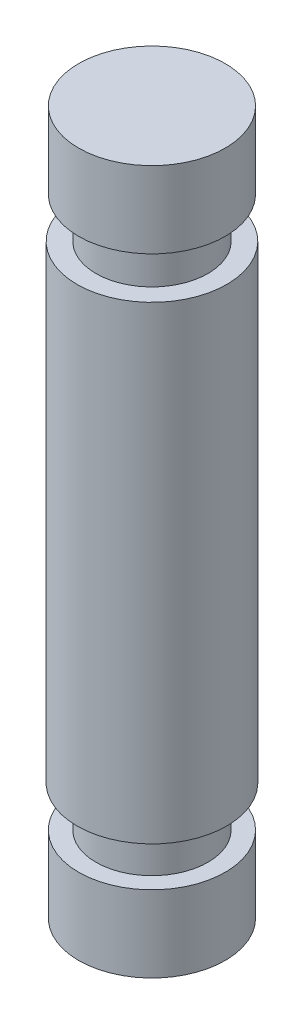
from build123d import *

# Parameters (mm, degrees)
SKETCH2_R           = 3.5
BOSS_EXTRUDE1_DEPTH = 3.65
SKETCH3_R           = 2.675
BOSS_EXTRUDE2_DEPTH = 1.95
SKETCH4_R           = 3.575
BOSS_EXTRUDE3_DEPTH = 22.4
SKETCH5_R           = 2.675
BOSS_EXTRUDE4_DEPTH = 1.95
SKETCH6_R           = 3.5
BOSS_EXTRUDE5_DEPTH = 3.65


with BuildPart() as part:
    # Sketch2 → Boss-Extrude1 (new body)
    with BuildSketch(Plane(origin=(0, 0, 0), x_dir=(1, 0, 0), z_dir=(0, 1, 0))):
        Circle(SKETCH2_R)
    extrude(amount=BOSS_EXTRUDE1_DEPTH)

    # Sketch3 → Boss-Extrude2 (add)
    with BuildSketch(Plane(origin=(0, 3.65, 0), x_dir=(1, 0, 0), z_dir=(0, 1, 0))):
        Circle(SKETCH3_R)
    extrude(amount=BOSS_EXTRUDE2_DEPTH)

    # Sketch4 → Boss-Extrude3 (add)
    with BuildSketch(Plane(origin=(0, 5.6, 0), x_dir=(1, 0, 0), z_dir=(0, 1, 0))):
        Circle(SKETCH4_R)
    extrude(amount=BOSS_EXTRUDE3_DEPTH)

    # Sketch5 → Boss-Extrude4 (add)
    with BuildSketch(Plane(origin=(0, 28, 0), x_dir=(1, 0, 0), z_dir=(0, 1, 0))):
        Circle(SKETCH5_R)
    extrude(amount=BOSS_EXTRUDE4_DEPTH)

    # Sketch6 → Boss-Extrude5 (add)
    with BuildSketch(Plane(origin=(0, 29.95, 0), x_dir=(1, 0, 0), z_dir=(0, 1, 0))):
        Circle(SKETCH6_R)
    extrude(amount=BOSS_EXTRUDE5_DEPTH)


solid = part.part
